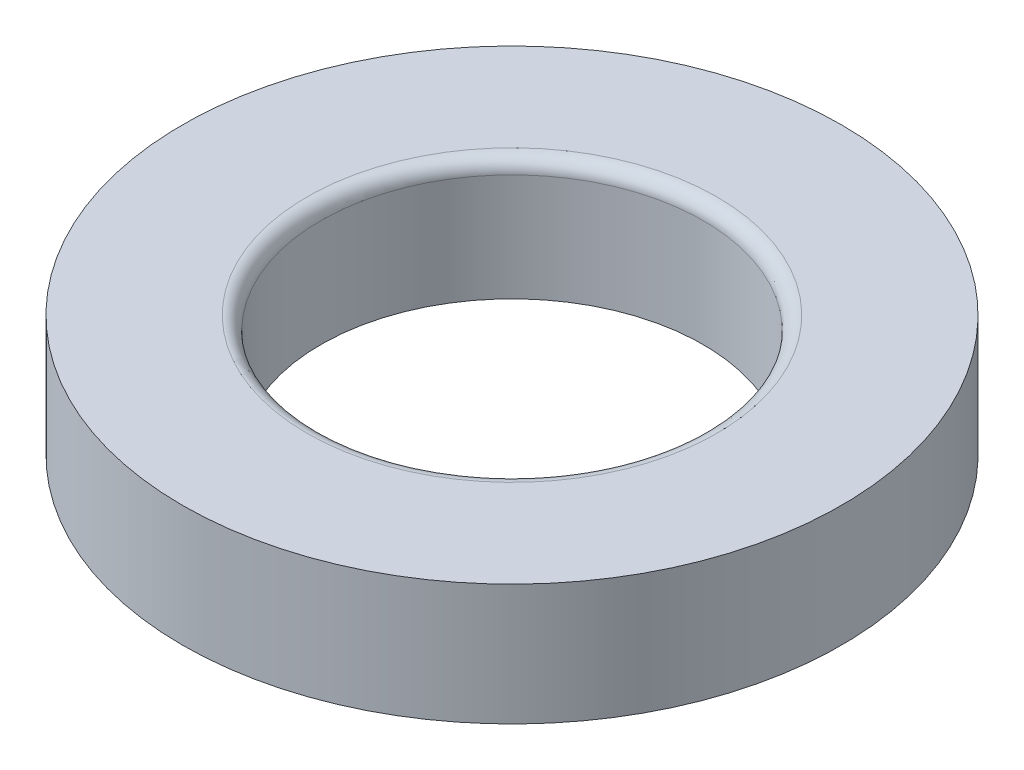
from build123d import *

# Parameters (mm, degrees)
SKETCH1_R           = 19.05
SKETCH1_R_2         = 11.05
BOSS_EXTRUDE1_DEPTH = 3.5000057
FILLET1_R           = 0.79375


with BuildPart() as part:
    # Sketch1 → Boss-Extrude1 (new body, symmetric)
    with BuildSketch(Plane(origin=(0, 0, 0), x_dir=(1, 0, 0), z_dir=(0, 1, 0))):
        Circle(SKETCH1_R)
        Circle(SKETCH1_R_2, mode=Mode.SUBTRACT)
    extrude(amount=BOSS_EXTRUDE1_DEPTH, both=True)

    # Fillet1
    fillet1_edges = [part.edges().sort_by_distance(p)[0] for p in [
        (-11.05, 3.5000057, 0),
    ]]
    fillet(fillet1_edges, radius=FILLET1_R)


solid = part.part
